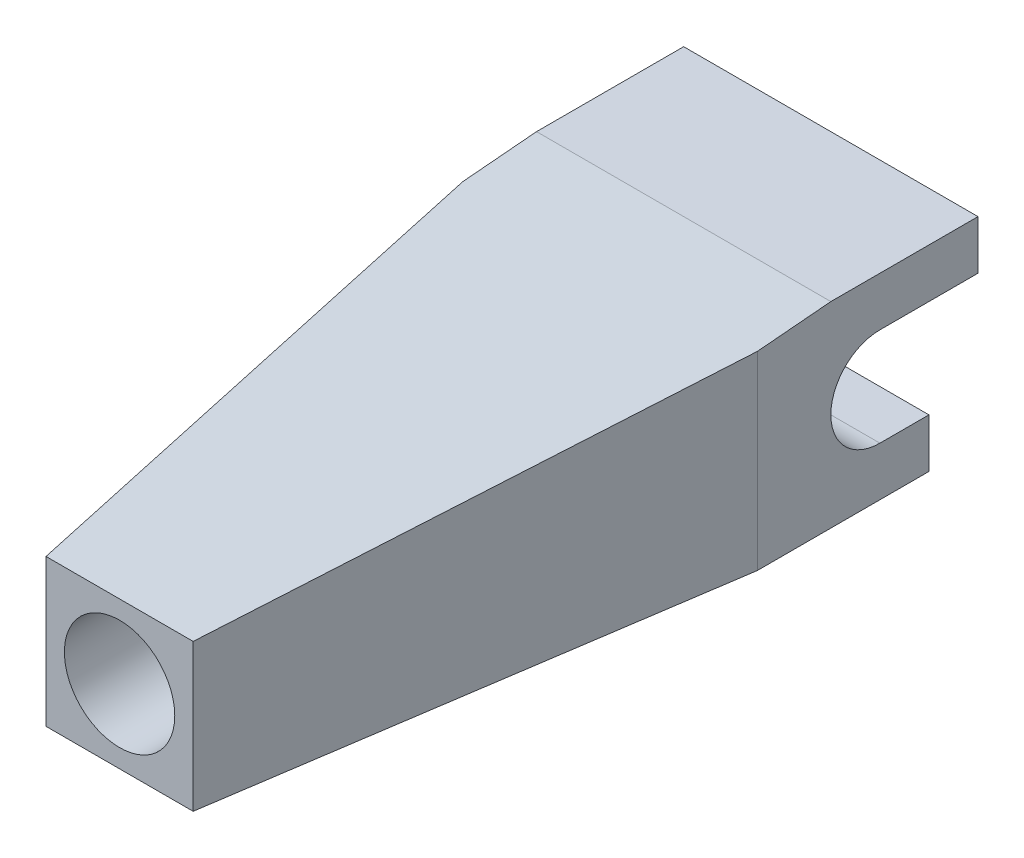
from build123d import *

# Parameters (mm, degrees)
EXTRUDE_1_DEPTH     = 12
CUT_EXTRUDE_1_DEPTH = 9
SKETCH_3_R          = 2.25
CUT_EXTRUDE_2_DEPTH = 20


with BuildPart() as part:
    # Эскиз1 → Бобышка-Вытянуть1 (new body)
    with BuildSketch(Plane(origin=(0, 0, 0), x_dir=(0, 0, -1), z_dir=(1, 0, 0))):
        with BuildLine():
            Line((0, 2), (0, -4))
            Line((0, -4), (27, -4))
            Line((27, -4), (27, -2))
            Line((27, -2), (25, -2))
            ThreePointArc((25, -2), (23, 0), (25, 2))
            Line((25, 2), (29, 2))
            Line((29, 2), (29, 4))
            Line((29, 4), (23, 4))
            Line((23, 4), (0, 2))
        make_face()
    extrude(amount=EXTRUDE_1_DEPTH)

    # Эскиз2 → Вырез-Вытянуть1 (cut, through all)
    with BuildSketch(Plane(origin=(0, 4, 0), x_dir=(1, 0, 0), z_dir=(0, 1, 0))):
        Polygon((0, 0), (0, 20), (3, 0), align=None)
        Polygon((12, 20), (9, 0), (12, 0), align=None)
    extrude(amount=-CUT_EXTRUDE_1_DEPTH, mode=Mode.SUBTRACT)

    # Эскиз3 → Вырез-Вытянуть2 (cut)
    with BuildSketch(Plane.XY):
        with Locations((6, -1)):
            Circle(SKETCH_3_R)
    extrude(amount=-CUT_EXTRUDE_2_DEPTH, mode=Mode.SUBTRACT)


solid = part.part
